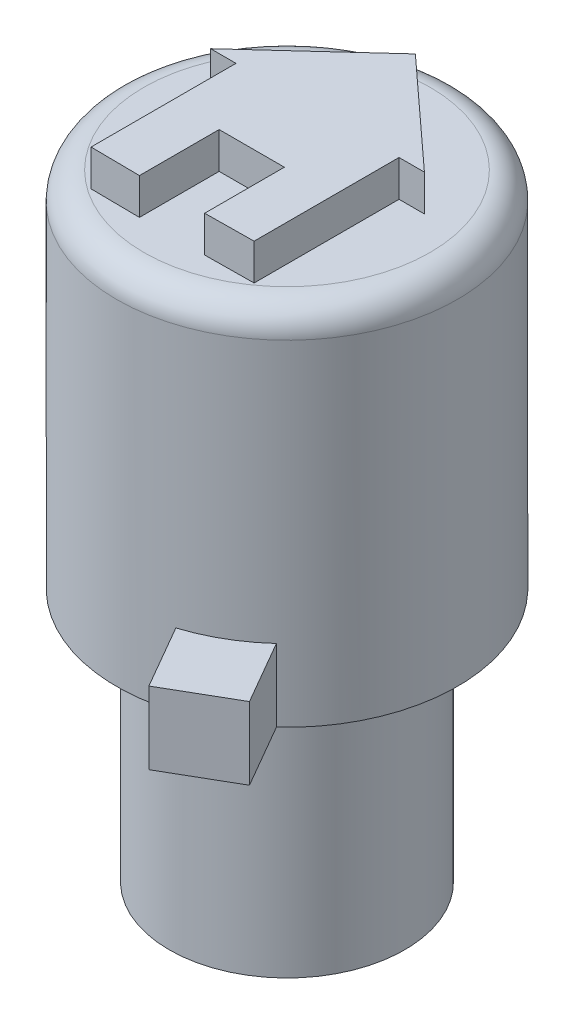
from build123d import *

# Parameters (mm, degrees)
SKETCH1_R           = 3.25
BOSS_EXTRUDE1_DEPTH = 7.018
SKETCH6_R           = 4.7
BOSS_EXTRUDE2_DEPTH = 10
BOSS_EXTRUDE3_DEPTH = 1
FILLET1_R           = 0.75
BOSS_EXTRUDE4_DEPTH = 2


with BuildPart() as part:
    # Sketch1 → Boss-Extrude1 (new body)
    with BuildSketch(Plane(origin=(0, 0, 0), x_dir=(1, 0, 0), z_dir=(0, 1, 0))):
        Circle(SKETCH1_R)
    extrude(amount=BOSS_EXTRUDE1_DEPTH)

    # Sketch6 → Boss-Extrude2 (add)
    with BuildSketch(Plane(origin=(0, 7.018, 0), x_dir=(1, 0, 0), z_dir=(0, 1, 0))):
        Circle(SKETCH6_R)
    extrude(amount=BOSS_EXTRUDE2_DEPTH)

    # Sketch12 → Boss-Extrude3 (add)
    with BuildSketch(Plane(origin=(0, 17.018, 0), x_dir=(1, 0, 0), z_dir=(0, 1, 0))):
        Polygon((0, 3.542487974), (-2.95, 0.842487974), (-2.25, 0.842487974), (-2.25, -3.157512026), (-0.9, -3.172366953), (-0.9, -0.972366953), (0.9, -0.972366953), (0.9, -3.172366953), (2.25, -3.157512026), (2.25, 0.842487974), (2.95, 0.842487974), align=None)
    extrude(amount=BOSS_EXTRUDE3_DEPTH)

    # Fillet1
    fillet1_edges = [part.edges().sort_by_distance(p)[0] for p in [
        (-4.7, 17.018, 0),
    ]]
    fillet(fillet1_edges, radius=FILLET1_R)

    # Sketch13 → Boss-Extrude4 (add)
    with BuildSketch(Plane.XZ.offset(-7.018)):
        with BuildLine():
            Line((-0.770430625, -4.636424986), (-1.786430625, -6.396188607))
            Line((-1.786430625, -6.396188607), (-4.646046508, -4.745188607))
            Line((-4.646046508, -4.745188607), (-3.630046508, -2.985424986))
            ThreePointArc((-3.630046508, -2.985424986), (-2.35, -4.070319398), (-0.770430625, -4.636424986))
        make_face()
        with BuildLine():
            Line((3.174317689, 3.466079516), (4.190317689, 5.225843137))
            Line((4.190317689, 5.225843137), (2.430554068, 6.241843137))
            Line((2.430554068, 6.241843137), (1.414554068, 4.482079516))
            ThreePointArc((1.414554068, 4.482079516), (2.35, 4.070319398), (3.174317689, 3.466079516))
        make_face()
    extrude(amount=-BOSS_EXTRUDE4_DEPTH)


solid = part.part
